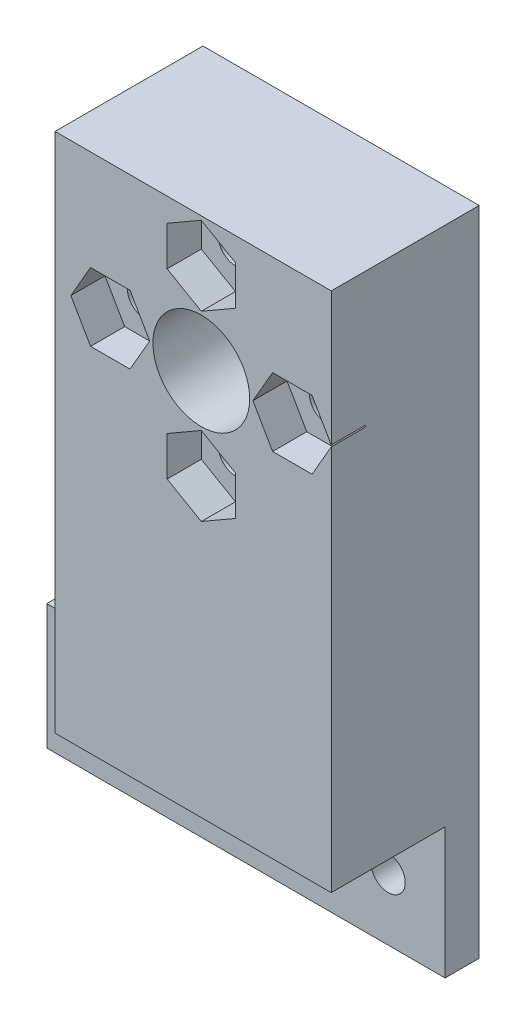
from build123d import *

# Parameters (mm, degrees)
SKETCH1_W           = 24.274152736
SKETCH1_H           = 45.799920806
SKETCH1_R           = 4.25
BOSS_EXTRUDE1_DEPTH = 2
SKETCH1_3_W         = 24.274152736
SKETCH1_3_H         = 2
SKETCH1_3_H_2       = 43.799920806
BOSS_EXTRUDE2_DEPTH = 8
BOSS_EXTRUDE3_START = -8
SKETCH1_4_W         = 24.274152736
SKETCH1_4_H         = 43.799920806
SKETCH1_4_W_2       = 10
SKETCH1_4_H_2       = 11
SKETCH1_4_H_3       = 2
SKETCH1_4_W_3       = 14.274152736
SKETCH1_4_R         = 1.5
SKETCH1_4_W_4       = 10.725847264
BOSS_EXTRUDE3_DEPTH = 3
SKETCH1_5_R         = 4.25
BOSS_EXTRUDE4_DEPTH = 11
SKETCH2_R           = 4.25
SKETCH2_R_2         = 1.5
CUT_EXTRUDE1_DEPTH  = 3
SKETCH2_2_R         = 1.5
CUT_EXTRUDE2_DEPTH  = 14


with BuildPart() as part:
    # Sketch1 → Boss-Extrude1 (new body)
    with BuildSketch(Plane.XY):
        with Locations((-69.637076368, 28.899960403)):
            Rectangle(SKETCH1_W, SKETCH1_H)
        with Locations((-68.922189075, 39.999920806)):
            Circle(SKETCH1_R, mode=Mode.SUBTRACT)
    extrude(amount=BOSS_EXTRUDE1_DEPTH)

    # Sketch1_3 → Boss-Extrude2 (add)
    with BuildSketch(Plane.XY):
        with Locations((-69.637076368, 7)):
            Rectangle(SKETCH1_3_W, SKETCH1_3_H)
        with Locations((-69.637076368, 29.899960403)):
            Rectangle(SKETCH1_3_W, SKETCH1_3_H_2)
        Polygon((-61.070225414, 39.999920806), (-64.996207244, 33.199920806), (-72.848170905, 33.199920806), (-76.774152736, 39.999920806), (-72.848170905, 46.799920806), (-64.996207244, 46.799920806), align=None, mode=Mode.SUBTRACT)
    extrude(amount=-BOSS_EXTRUDE2_DEPTH)

    # Sketch1_4 → Boss-Extrude3 (add)
    with BuildSketch(Plane.XY.offset(BOSS_EXTRUDE3_START)):
        with Locations((-69.637076368, 29.899960403)):
            Rectangle(SKETCH1_4_W, SKETCH1_4_H)
        Polygon((-61.070225414, 39.999920806), (-64.996207244, 33.199920806), (-72.848170905, 33.199920806), (-76.774152736, 39.999920806), (-72.848170905, 46.799920806), (-64.996207244, 46.799920806), align=None, mode=Mode.SUBTRACT)
        with Locations((-62.5, 0)):
            Rectangle(SKETCH1_4_W_2, SKETCH1_4_H_2)
        Polygon((-59.035898385, 0), (-60.767949192, 3), (-64.232050808, 3), (-65.964101615, 0), (-64.232050808, -3), (-60.767949192, -3), align=None, mode=Mode.SUBTRACT)
        Polygon((-67.5, 5.5), (-57.5, 5.5), (-57.5, 6), (-81.774152736, 6), (-81.774152736, 5.5), align=None)
        with Locations((-69.637076368, 7)):
            Rectangle(SKETCH1_4_W, SKETCH1_4_H_3)
        with Locations((-74.637076368, 0)):
            Rectangle(SKETCH1_4_W_3, SKETCH1_4_H_2)
        Polygon((-60.767949192, -3), (-59.035898385, 0), (-60.767949192, 3), (-64.232050808, 3), (-65.964101615, 0), (-64.232050808, -3), align=None)
        with Locations((-62.5, 0)):
            Circle(SKETCH1_4_R, mode=Mode.SUBTRACT)
        with Locations((-87.137076368, 0)):
            Rectangle(SKETCH1_4_W_4, SKETCH1_4_H_2)
        Polygon((-90.5, -1.732050808), (-87.5, -3.464101615), (-84.5, -1.732050808), (-84.5, 1.732050808), (-87.5, 3.464101615), (-90.5, 1.732050808), align=None, mode=Mode.SUBTRACT)
        Polygon((-90.5, 1.732050808), (-90.5, -1.732050808), (-87.5, -3.464101615), (-84.5, -1.732050808), (-84.5, 1.732050808), (-87.5, 3.464101615), align=None)
        with Locations((-87.5, 0)):
            Circle(SKETCH1_4_R, mode=Mode.SUBTRACT)
    extrude(amount=-BOSS_EXTRUDE3_DEPTH)

    # Sketch1_5 → Boss-Extrude4 (add)
    with BuildSketch(Plane.XY):
        Polygon((-76.774152736, 39.999920806), (-72.848170905, 33.199920806), (-64.996207244, 33.199920806), (-61.070225414, 39.999920806), (-64.996207244, 46.799920806), (-72.848170905, 46.799920806), align=None)
        with Locations((-68.922189075, 39.999920806)):
            Circle(SKETCH1_5_R, mode=Mode.SUBTRACT)
    extrude(amount=-BOSS_EXTRUDE4_DEPTH)

    # Sketch2 → Cut-Extrude1 (cut)
    with BuildSketch(Plane.XY.offset(2)):
        with Locations((-68.922189075, 39.999920806)):
            Circle(SKETCH2_R)
        Polygon((-73.45808746, 39.999920806), (-75.190138267, 42.999920806), (-78.654239882, 42.999920806), (-80.38629069, 39.999920806), (-78.654239882, 36.999920806), (-75.190138267, 36.999920806), align=None)
        with Locations((-76.922189075, 39.999920806)):
            Circle(SKETCH2_R_2, mode=Mode.SUBTRACT)
        Polygon((-68.922189075, 28.535819191), (-65.922189075, 30.267869999), (-65.922189075, 33.731971614), (-68.922189075, 35.464022422), (-71.922189075, 33.731971614), (-71.922189075, 30.267869999), align=None)
        with Locations((-68.922189075, 31.999920806)):
            Circle(SKETCH2_R_2, mode=Mode.SUBTRACT)
        Polygon((-68.922189075, 44.535819191), (-65.922189075, 46.267869999), (-65.922189075, 49.731971614), (-68.922189075, 51.464022422), (-71.922189075, 49.731971614), (-71.922189075, 46.267869999), align=None)
        with Locations((-68.922189075, 47.999920806)):
            Circle(SKETCH2_R_2, mode=Mode.SUBTRACT)
        Polygon((-64.38629069, 39.999920806), (-62.654239882, 36.999920806), (-59.190138267, 36.999920806), (-57.45808746, 39.999920806), (-59.190138267, 42.999920806), (-62.654239882, 42.999920806), align=None)
        with Locations((-60.922189075, 39.999920806)):
            Circle(SKETCH2_R_2, mode=Mode.SUBTRACT)
    extrude(amount=-CUT_EXTRUDE1_DEPTH, mode=Mode.SUBTRACT)

    # Sketch2_2 → Cut-Extrude2 (cut, through all)
    with BuildSketch(Plane.XY.offset(2)):
        with Locations((-60.922189075, 39.999920806)):
            Circle(SKETCH2_2_R)
        with Locations((-68.922189075, 47.999920806)):
            Circle(SKETCH2_2_R)
        with Locations((-76.922189075, 39.999920806)):
            Circle(SKETCH2_2_R)
        with Locations((-68.922189075, 31.999920806)):
            Circle(SKETCH2_2_R)
    extrude(amount=-CUT_EXTRUDE2_DEPTH, mode=Mode.SUBTRACT)


solid = part.part
